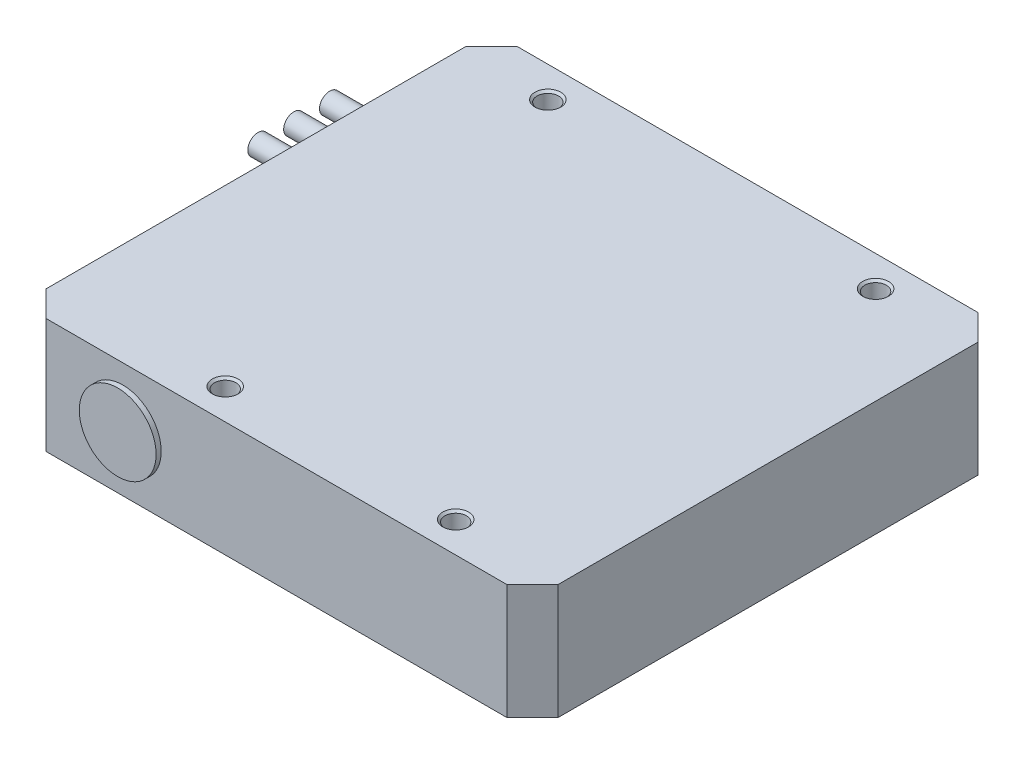
from build123d import *

# Parameters (mm, degrees)
SKETCH1_W                   = 100
SKETCH1_H                   = 92
BOSS_EXTRUDE1_DEPTH         = 22.5
CHAMFER1_SIZE               = 5
SKETCH3_R                   = 7.5
BOSS_EXTRUDE2_DEPTH         = 1
M5_TAPPED_HOLE1_D           = 4.2
M5_TAPPED_HOLE1_DEPTH       = 5
M5_TAPPED_HOLE1_CSINK_D     = 5.05
M5_TAPPED_HOLE1_CSINK_ANGLE = 90
M5_TAPPED_HOLE1_TIP         = 1.2618073
SKETCH8_R                   = 2
BOSS_EXTRUDE3_DEPTH         = 15


with BuildPart() as part:
    # Sketch1 → Boss-Extrude1 (new body)
    with BuildSketch(Plane(origin=(0, 0, 0), x_dir=(1, 0, 0), z_dir=(0, 1, 0))):
        Rectangle(SKETCH1_W, SKETCH1_H)
    extrude(amount=BOSS_EXTRUDE1_DEPTH)

    # Chamfer1
    chamfer1_edges = [part.edges().sort_by_distance(p)[0] for p in [
        (50, 11.25, 46),
        (-50, 11.25, 46),
        (-50, 11.25, -46),
        (50, 11.25, -46),
    ]]
    chamfer(chamfer1_edges, length=CHAMFER1_SIZE)

    # Sketch3 → Boss-Extrude2 (add)
    with BuildSketch(Plane.XY.offset(46)):
        with Locations((-30, 11.25)):
            Circle(SKETCH3_R)
    extrude(amount=BOSS_EXTRUDE2_DEPTH)

    # M5 Tapped Hole1
    with Locations(Plane(origin=(0, 22.5, 0), x_dir=(1, 0, 0), z_dir=(0, 1, 0))):
        with Locations((-33, 40), (31, 40), (29, -40), (-16, -40)):
            CounterSinkHole(M5_TAPPED_HOLE1_D / 2, M5_TAPPED_HOLE1_CSINK_D / 2, depth=M5_TAPPED_HOLE1_DEPTH, counter_sink_angle=M5_TAPPED_HOLE1_CSINK_ANGLE)
            with Locations((0, 0, -(M5_TAPPED_HOLE1_DEPTH + M5_TAPPED_HOLE1_TIP / 2))):  # 118° drill point
                Cone(0, M5_TAPPED_HOLE1_D / 2, M5_TAPPED_HOLE1_TIP, mode=Mode.SUBTRACT)

    # Sketch8 → Boss-Extrude3 (add)
    with BuildSketch(Plane.ZY.offset(50)):
        with Locations((-29.407923946, 11.25)):
            Circle(SKETCH8_R)
        with Locations((-22.407923946, 11.25)):
            Circle(SKETCH8_R)
        with Locations((-15.407923946, 11.25)):
            Circle(SKETCH8_R)
    extrude(amount=BOSS_EXTRUDE3_DEPTH)


solid = part.part
